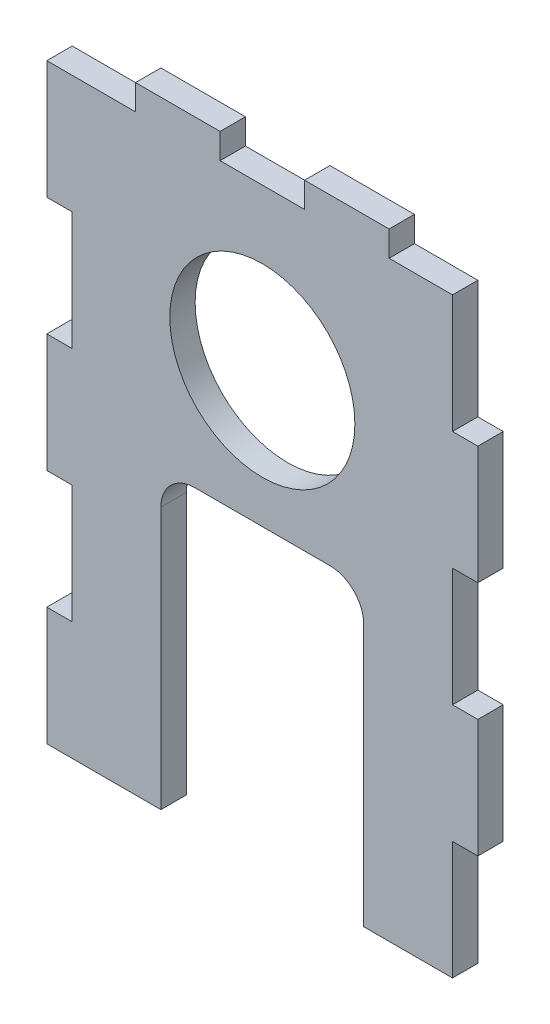
from build123d import *

# Parameters (mm, degrees)
SKETCH1_W           = 45
SKETCH1_H           = 70
BOSS_EXTRUDE1_DEPTH = 3
SKETCH2_R           = 10.95
SKETCH2_W           = 24
SKETCH2_H           = 35
CUT_EXTRUDE1_DEPTH  = 4
FILLET1_R           = 4
SKETCH4_W           = 10
SKETCH4_H           = 3
BOSS_EXTRUDE3_DEPTH = 3
SKETCH3_W           = 3
SKETCH3_H           = 14
BOSS_EXTRUDE2_DEPTH = 3


with BuildPart() as part:
    # Sketch1 → Boss-Extrude1 (new body)
    with BuildSketch(Plane.XY):
        Rectangle(SKETCH1_W, SKETCH1_H)
    extrude(amount=BOSS_EXTRUDE1_DEPTH)

    # Sketch2 → Cut-Extrude1 (cut, through all)
    with BuildSketch(Plane.XY.offset(3)):
        with Locations((0, 16)):
            Circle(SKETCH2_R)
        with Locations((0, -17.5)):
            Rectangle(SKETCH2_W, SKETCH2_H)
    extrude(amount=-CUT_EXTRUDE1_DEPTH, mode=Mode.SUBTRACT)

    # Fillet1
    fillet1_edges = [part.edges().sort_by_distance(p)[0] for p in [
        (12, 0, 1.5),
        (-12, 0, 1.5),
    ]]
    fillet(fillet1_edges, radius=FILLET1_R)

    # Sketch4 → Boss-Extrude3 (add)
    with BuildSketch(Plane.XY.offset(3)):
        with Locations((-10, 36.5)):
            Rectangle(SKETCH4_W, SKETCH4_H)
        with Locations((10, 36.5)):
            Rectangle(SKETCH4_W, SKETCH4_H)
    extrude(amount=-BOSS_EXTRUDE3_DEPTH)

    # Sketch3 → Boss-Extrude2 (add)
    with BuildSketch(Plane(origin=(0, 0, 0), x_dir=(-1, 0, 0), z_dir=(0, 0, -1))):
        with Locations((24, 0)):
            Rectangle(SKETCH3_W, SKETCH3_H)
        with Locations((24, 28)):
            Rectangle(SKETCH3_W, SKETCH3_H)
        with Locations((24, -28)):
            Rectangle(SKETCH3_W, SKETCH3_H)
        with Locations((-24, 14)):
            Rectangle(SKETCH3_W, SKETCH3_H)
        with Locations((-24, -14)):
            Rectangle(SKETCH3_W, SKETCH3_H)
    extrude(amount=-BOSS_EXTRUDE2_DEPTH)


solid = part.part
